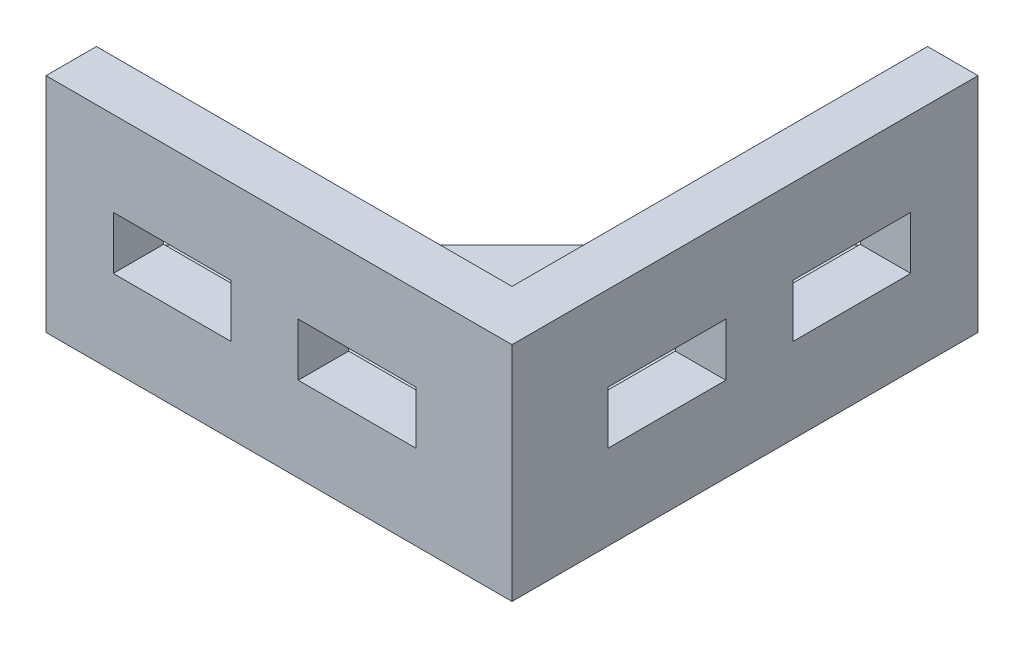
from build123d import *

# Parameters (mm, degrees)
BOSS_EXTRUDE1_DEPTH = 42
BOSS_EXTRUDE2_DEPTH = 9.525
SKETCH3_W           = 22.225
SKETCH3_H           = 10
CUT_EXTRUDE1_DEPTH  = 9.525
SKETCH4_W           = 22.225
SKETCH4_H           = 10
CUT_EXTRUDE2_DEPTH  = 9.525


with BuildPart() as part:
    # Sketch1 → Boss-Extrude1 (new body)
    with BuildSketch(Plane(origin=(0, 0, 0), x_dir=(1, 0, 0), z_dir=(0, 1, 0))):
        Polygon((0, 0), (-88, 0), (-88, 9.525), (-9.525, 9.525), (-9.525, 88), (0, 88), align=None)
    extrude(amount=BOSS_EXTRUDE1_DEPTH)

    # Sketch2 → Boss-Extrude2 (add)
    with BuildSketch(Plane(origin=(0, 0, 0), x_dir=(1, 0, 0), z_dir=(0, 1, 0))):
        Polygon((-9.525, 88), (-88, 9.525), (-9.525, 9.525), align=None)
    extrude(amount=BOSS_EXTRUDE2_DEPTH)

    # Sketch3 → Cut-Extrude1 (cut)
    with BuildSketch(Plane(origin=(0, 0, -9.525), x_dir=(-1, 0, 0), z_dir=(0, 0, -1))):
        with Locations((29.2625, 21)):
            Rectangle(SKETCH3_W, SKETCH3_H)
        with Locations((64.1875, 21)):
            Rectangle(SKETCH3_W, SKETCH3_H)
    extrude(amount=-CUT_EXTRUDE1_DEPTH, mode=Mode.SUBTRACT)

    # Sketch4 → Cut-Extrude2 (cut)
    with BuildSketch(Plane.ZY.offset(9.525)):
        with Locations((-29.2625, 21)):
            Rectangle(SKETCH4_W, SKETCH4_H)
        with Locations((-64.1875, 21)):
            Rectangle(SKETCH4_W, SKETCH4_H)
    extrude(amount=-CUT_EXTRUDE2_DEPTH, mode=Mode.SUBTRACT)


solid = part.part
